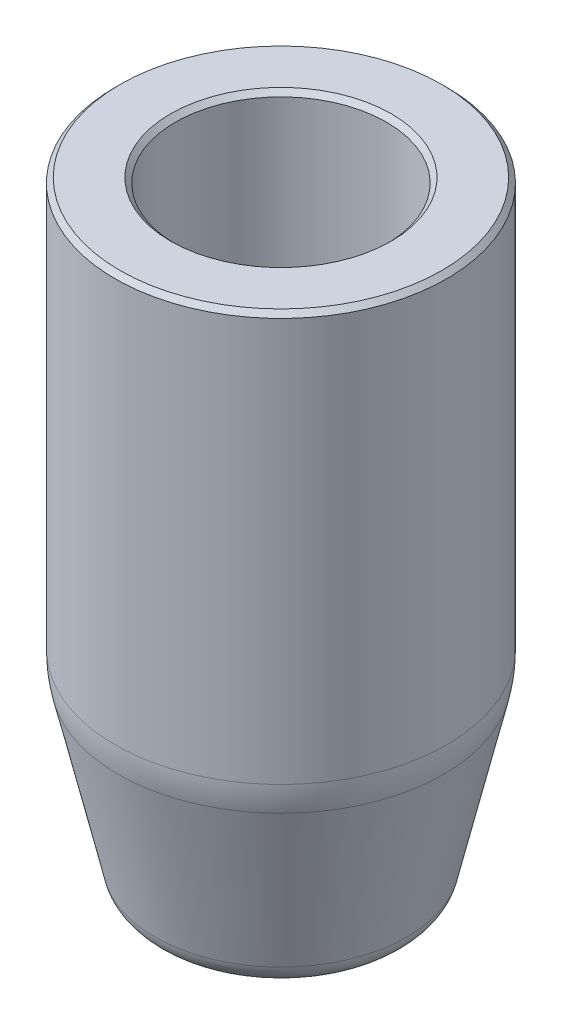
from build123d import *

# Parameters (mm, degrees)
FILLET2_R     = 6.35
FILLET3_R     = 1.5875
FILLET1_R     = 0.79375
CHAMFER1_SIZE = 0.254


with BuildPart() as part:
    # Sketch1 → Revolve1 (revolve)
    with BuildSketch(Plane.XY):
        Polygon((8.73125, 32.54375), (5.55625, 32.54375), (5.55625, 10.31875), (3.96875, 10.31875), (3.96875, 3.175), (2.38125, 3.175), (2.38125, 0), (6.35, 0), (8.73125, 10.31875), align=None)
    revolve(axis=Axis((0, 4.297998533, 0), (0, -1, 0)))

    # Fillet2
    fillet2_edges = [part.edges().sort_by_distance(p)[0] for p in [
        (-8.73125, 10.31875, 0),
    ]]
    fillet(fillet2_edges, radius=FILLET2_R)

    # Fillet3
    fillet3_edges = [part.edges().sort_by_distance(p)[0] for p in [
        (-6.35, 0, 0),
    ]]
    fillet(fillet3_edges, radius=FILLET3_R)

    # Fillet1
    fillet1_edges = [part.edges().sort_by_distance(p)[0] for p in [
        (-5.55625, 10.31875, 0),
        (-3.96875, 3.175, 0),
    ]]
    fillet(fillet1_edges, radius=FILLET1_R)

    # Chamfer1
    chamfer1_edges = [part.edges().sort_by_distance(p)[0] for p in [
        (-2.38125, 0, 0),
        (-8.73125, 32.54375, 0),
        (-5.55625, 32.54375, 0),
        (-3.96875, 10.31875, 0),
        (-2.38125, 3.175, 0),
    ]]
    chamfer(chamfer1_edges, length=CHAMFER1_SIZE)


solid = part.part
